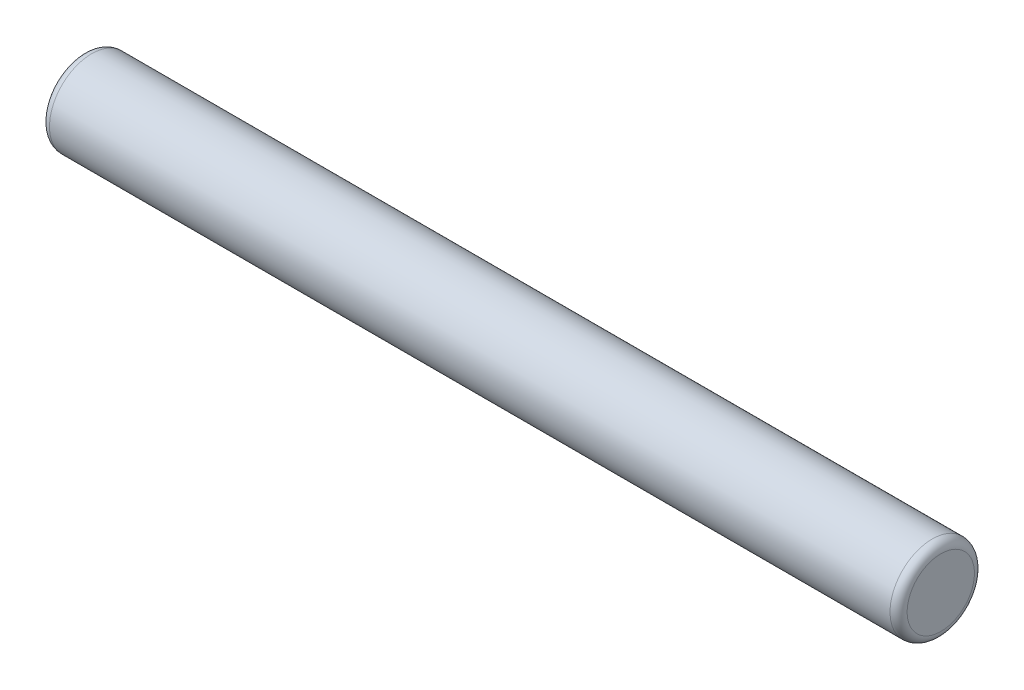
from build123d import *

# Parameters (mm, degrees)
SKETCH1_R           = 2.5
BOSS_EXTRUDE1_DEPTH = 50.8
FILLET1_R           = 0.508


with BuildPart() as part:
    # Sketch1 → Boss-Extrude1 (new body)
    with BuildSketch(Plane(origin=(0, 0, 0), x_dir=(0, 0, -1), z_dir=(1, 0, 0))):
        Circle(SKETCH1_R)
    extrude(amount=BOSS_EXTRUDE1_DEPTH)

    # Fillet1
    fillet1_edges = [part.edges().sort_by_distance(p)[0] for p in [
        (0, 0, 2.5),
        (50.8, 0, 2.5),
    ]]
    fillet(fillet1_edges, radius=FILLET1_R)


solid = part.part
